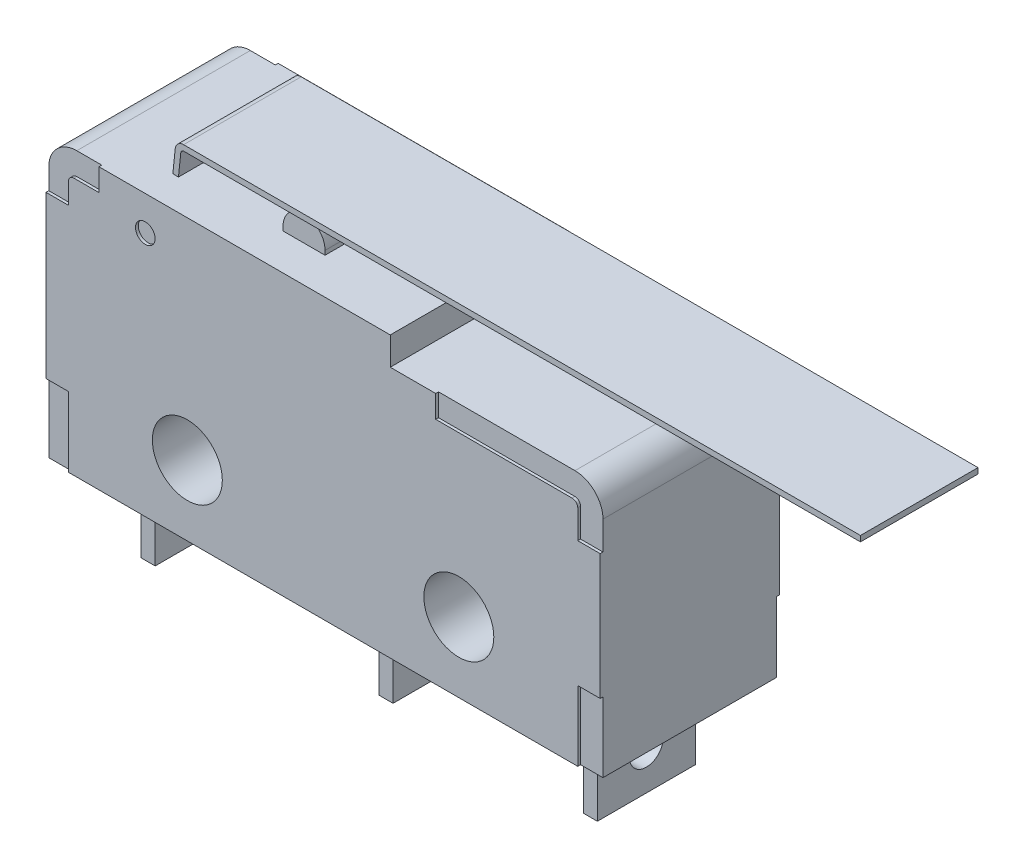
from build123d import *

# Parameters (mm, degrees)
EXTRUDE1_DEPTH           = 3.2
EXTRUDE1_DEPTH_BACK      = 3.2
SKETCH1_R                = 1.25
FILLET1_R                = 1
CUT_EXTRUDE1_DEPTH       = 0.1
CUT_EXTRUDE2_START       = -0.1
CUT_EXTRUDE2_DEPTH       = 0.1
EXTRUDE3_DEPTH           = 1.75
EXTRUDE3_DEPTH_BACK      = 1.75
CUT_EXTRUDE3_DEPTH       = 13.825755338
CUT_EXTRUDE3_DEPTH_BACK  = 13.825755338
SKETCH6_R                = 0.6
SKETCH8_R                = 0.35
CUT_EXTRUDE4_DEPTH       = 0.1
CUT_EXTRUDE5_START       = -0.1
SKETCH9_R                = 0.35
CUT_EXTRUDE5_DEPTH       = 0.1
EXTRUDE4_DEPTH           = 1.9
EXTRUDE4_DEPTH_BACK      = 1.9
EXTRUDE_THIN3_DEPTH      = 2.1
EXTRUDE_THIN3_DEPTH_BACK = 2.1
FILLET6_R                = 0.1
FILLET7_R                = 0.3


with BuildPart() as part:
    # Sketch1 → Extrude1 (new, two sides: drawn at the far end of the back side and taken through both)
    with BuildSketch(Plane.XY.offset(-EXTRUDE1_DEPTH_BACK)):
        Polygon((-9.9, 7.5), (2.4, 7.5), (2.4, 6.5), (9.9, 6.5), (9.9, -2.5), (-9.9, -2.5), align=None)
        with Locations((-4.85, 0)):
            Circle(SKETCH1_R, mode=Mode.SUBTRACT)
        with Locations((4.85, 0)):
            Circle(SKETCH1_R, mode=Mode.SUBTRACT)
    extrude(amount=EXTRUDE1_DEPTH + EXTRUDE1_DEPTH_BACK)

    # Fillet1
    fillet1_edges = [part.edges().sort_by_distance(p)[0] for p in [
        (-9.9, 7.5, 0),
        (9.9, 6.5, 0),
    ]]
    fillet(fillet1_edges, radius=FILLET1_R)

    # Sketch2 → Cut-Extrude1 (cut)
    with BuildSketch(Plane.XY.offset(3.2)):
        with BuildLine():
            Line((8.9, 6.5), (4.024187691, 6.5))
            Line((4.024187691, 6.5), (4.024187691, 5.7))
            Line((4.024187691, 5.7), (8.9, 5.7))
            ThreePointArc((8.9, 5.7), (9.041421356, 5.641421356), (9.1, 5.5))
            Line((9.1, 5.5), (9.1, 4.482655552))
            Line((9.1, 4.482655552), (9.9, 4.482655552))
            Line((9.9, 4.482655552), (9.9, 5.5))
            ThreePointArc((9.9, 5.5), (9.607106781, 6.207106781), (8.9, 6.5))
        make_face()
        Polygon((9.9, -2.5), (9.9, 0), (9.1, 0), (9.1, -1.7), (9.1, -2.5), align=None)
        Polygon((-9.9, -2.5), (-9.1, -2.5), (-9.1, -1.7), (-9.1, 0), (-9.9, 0), align=None)
        with BuildLine():
            Line((-8.006418485, 7.5), (-8.9, 7.5))
            ThreePointArc((-8.9, 7.5), (-9.607106781, 7.207106781), (-9.9, 6.5))
            Line((-9.9, 6.5), (-9.9, 5.761874198))
            Line((-9.9, 5.761874198), (-9.1, 5.761874198))
            Line((-9.1, 5.761874198), (-9.1, 6.5))
            ThreePointArc((-9.1, 6.5), (-9.041421356, 6.641421356), (-8.9, 6.7))
            Line((-8.9, 6.7), (-8.006418485, 6.7))
            Line((-8.006418485, 6.7), (-8.006418485, 7.5))
        make_face()
    extrude(amount=-CUT_EXTRUDE1_DEPTH, mode=Mode.SUBTRACT)

    # Sketch3 → Cut-Extrude2 (cut)
    with BuildSketch(Plane(origin=(0, 0, -3.2), x_dir=(-1, 0, 0), z_dir=(0, 0, -1)).offset(CUT_EXTRUDE2_START)):
        with BuildLine():
            Line((8.9, 7.5), (8.006418485, 7.5))
            Line((8.006418485, 7.5), (8.006418485, 6.7))
            Line((8.006418485, 6.7), (8.9, 6.7))
            ThreePointArc((8.9, 6.7), (9.041421356, 6.641421356), (9.1, 6.5))
            Line((9.1, 6.5), (9.1, 5.761874198))
            Line((9.1, 5.761874198), (9.9, 5.761874198))
            Line((9.9, 5.761874198), (9.9, 6.5))
            ThreePointArc((9.9, 6.5), (9.607106781, 7.207106781), (8.9, 7.5))
        make_face()
        Polygon((9.1, -1.7), (9.1, -2.5), (9.9, -2.5), (9.9, 0), (9.1, 0), align=None)
        Polygon((-9.9, 0), (-9.9, -2.5), (-9.1, -2.5), (-9.1, -1.7), (-9.1, 0), align=None)
        with BuildLine():
            Line((-4.024187691, 5.7), (-4.024187691, 6.5))
            Line((-4.024187691, 6.5), (-8.9, 6.5))
            ThreePointArc((-8.9, 6.5), (-9.607106781, 6.207106781), (-9.9, 5.5))
            Line((-9.9, 5.5), (-9.9, 4.482655552))
            Line((-9.9, 4.482655552), (-9.1, 4.482655552))
            Line((-9.1, 4.482655552), (-9.1, 5.5))
            ThreePointArc((-9.1, 5.5), (-9.041421356, 5.641421356), (-8.9, 5.7))
            Line((-8.9, 5.7), (-4.024187691, 5.7))
        make_face()
    extrude(amount=CUT_EXTRUDE2_DEPTH, mode=Mode.SUBTRACT)

    # Sketch5 → Extrude3 (add, two sides: drawn at the far end of the back side and taken through both)
    with BuildSketch(Plane.XY.offset(-EXTRUDE3_DEPTH_BACK)):
        Polygon((-7.95, -2.5), (-7.7, -2.5), (-7.45, -2.5), (-7.45, -5.3), (-7.95, -5.3), align=None)
        Polygon((8.1, -2.5), (8.35, -2.5), (8.35, -5.3), (7.85, -5.3), (7.85, -2.5), align=None)
        Polygon((0.55, -2.5), (0.8, -2.5), (1.05, -2.5), (1.05, -5.3), (0.55, -5.3), align=None)
    extrude(amount=EXTRUDE3_DEPTH + EXTRUDE3_DEPTH_BACK)

    # Sketch6 → Cut-Extrude3 (cut, two sides: drawn at the far end of the back side and taken through both)
    with BuildSketch(Plane(origin=(0, 0, 0), x_dir=(0, 0, -1), z_dir=(1, 0, 0)).offset(-CUT_EXTRUDE3_DEPTH_BACK)):
        with Locations((0, -3.9)):
            Circle(SKETCH6_R)
    extrude(amount=CUT_EXTRUDE3_DEPTH + CUT_EXTRUDE3_DEPTH_BACK, mode=Mode.SUBTRACT)

    # Sketch8 → Cut-Extrude4 (cut)
    with BuildSketch(Plane.XY.offset(3.2)):
        with Locations((-6.351950972, 6.27426345)):
            Circle(SKETCH8_R)
    extrude(amount=-CUT_EXTRUDE4_DEPTH, mode=Mode.SUBTRACT)

    # Sketch9 → Cut-Extrude5 (cut)
    with BuildSketch(Plane(origin=(0, 0, -3.2), x_dir=(-1, 0, 0), z_dir=(0, 0, -1)).offset(CUT_EXTRUDE5_START)):
        with Locations((6.351950972, 6.27426345)):
            Circle(SKETCH9_R)
    extrude(amount=CUT_EXTRUDE5_DEPTH, mode=Mode.SUBTRACT)

    # Sketch11 → Extrude4 (add, two sides: drawn at the far end of the back side and taken through both)
    with BuildSketch(Plane.XY.offset(-EXTRUDE4_DEPTH_BACK)):
        with BuildLine():
            Line((-2.73, 7.65), (-2.73, 6.9))
            Line((-2.73, 6.9), (-1.23, 6.9))
            Line((-1.23, 6.9), (-1.23, 7.65))
            ThreePointArc((-1.23, 7.65), (-1.98, 8.4), (-2.73, 7.65))
        make_face()
    extrude(amount=EXTRUDE4_DEPTH + EXTRUDE4_DEPTH_BACK)

    # Sketch12 → Extrude-Thin3 (add, two sides: drawn at the far end of the back side and taken through both)
    with BuildSketch(Plane.XY.offset(-EXTRUDE_THIN3_DEPTH_BACK)):
        Polygon((-6.268968863, 7.489547154), (-6.173852185, 8.394521895), (18.1, 8.394521895), (18.1, 8.594521895), (-6.353932994, 8.594521895), (-6.467873242, 7.510452846), align=None)
    extrude(amount=EXTRUDE_THIN3_DEPTH + EXTRUDE_THIN3_DEPTH_BACK)

    # Fillet6
    fillet6_edges = [part.edges().sort_by_distance(p)[0] for p in [
        (-6.173852185, 8.394521895, 0),
    ]]
    fillet(fillet6_edges, radius=FILLET6_R)

    # Fillet7
    fillet7_edges = [part.edges().sort_by_distance(p)[0] for p in [
        (-6.353932994, 8.594521895, 0),
    ]]
    fillet(fillet7_edges, radius=FILLET7_R)


solid = part.part
